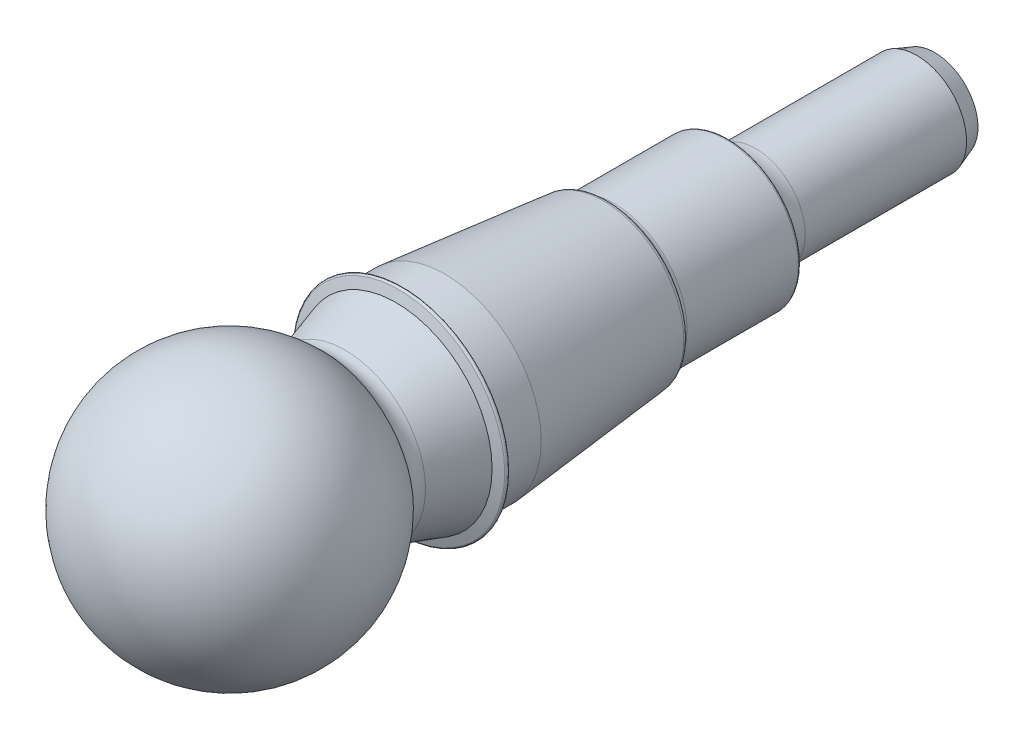
from build123d import *


with BuildPart() as part:
    # Skizze1 → Rotation1 (revolve)
    with BuildSketch(Plane(origin=(0, 0, 0), x_dir=(0, 0, -1), z_dir=(1, 0, 0)), mode=Mode.PRIVATE) as rotation1_sk:
        with BuildLine():
            Line((23.650537812, 10.6), (19.3, 10.6))
            Line((19.3, 10.6), (19.033380814, 11.595036348))
            ThreePointArc((19.033380814, 11.595036348), (18.835989234, 11.749950245), (18.632028278, 11.603793891))
            Line((18.632028278, 11.603793891), (18.3, 10.550734731))
            Line((18.3, 10.550734731), (12.695903498, 8.837390488))
            ThreePointArc((12.695903498, 8.837390488), (11.299257322, 8.922210653), (10.3, 9.901649168))
            ThreePointArc((10.3, 9.901649168), (-5.337199933, 13.253186527), (-14.2875, 0))
            Line((-14.2875, 0), (77.5, 0))
            Line((77.5, 0), (77.5, 4.75))
            Line((77.5, 4.75), (75.521816258, 5.47))
            Line((75.521816258, 5.47), (57.8, 5.47))
            ThreePointArc((57.8, 5.47), (56.980351785, 5.548751958), (56.190692742, 5.782126469))
            ThreePointArc((56.190692742, 5.782126469), (55.712862497, 6.032111847), (55.293450836, 6.371093101))
            ThreePointArc((55.293450836, 6.371093101), (55.076973377, 6.629792883), (54.913495432, 6.924857332))
            ThreePointArc((54.913495432, 6.924857332), (54.828674834, 7.19158406), (54.8, 7.47))
            Line((54.8, 7.47), (54.8, 7.7))
            ThreePointArc((54.8, 7.7), (54.712132034, 7.912132034), (54.5, 8))
            Line((54.5, 8), (42.277132939, 8))
            ThreePointArc((42.277132939, 8), (41.902132939, 8.100480947), (41.627613886, 8.375))
            Line((41.627613886, 8.375), (41.519615242, 8.562059138))
            ThreePointArc((41.519615242, 8.562059138), (41.325511547, 8.766085162), (41.059702303, 8.859081445))
            Line((41.059702303, 8.859081445), (23.650537812, 10.6))
        make_face()
    revolve(rotation1_sk.sketch.rotate(Axis((0, 0, 20.283583407), (0, 0, -1)), 90), axis=Axis((0, 0, 20.283583407), (0, 0, -1)))  # turned: the seam where the file's is


solid = part.part
